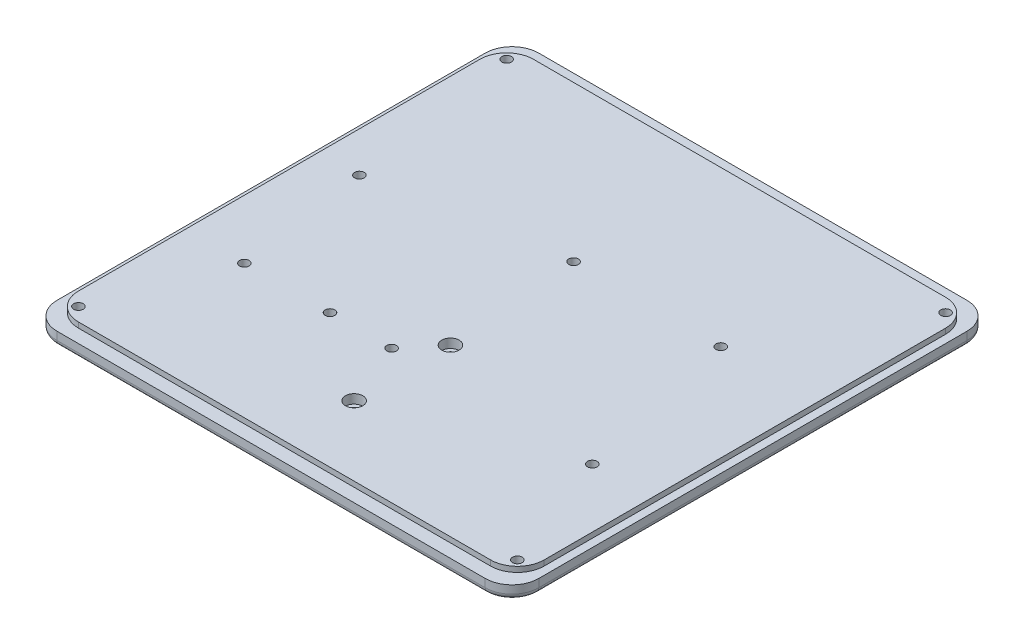
from build123d import *

# Parameters (mm, degrees)
SKIZZE1_W                                            = 180
SKIZZE1_H                                            = 180
AUFSATZ_LINEAR_AUSTRAGEN1_DEPTH                      = 5
AUFSATZ_LINEAR_AUSTRAGEN2_DEPTH                      = 2
STIRNSENKUNG_F_R_M3_ZYLINDERSCHRAUBE_MIT_D           = 3.6
STIRNSENKUNG_F_R_M3_ZYLINDERSCHRAUBE_MIT_DEPTH       = 9.1
STIRNSENKUNG_F_R_M3_ZYLINDERSCHRAUBE_MIT_CBORE_D     = 6.5
STIRNSENKUNG_F_R_M3_ZYLINDERSCHRAUBE_MIT_CBORE_DEPTH = 3.4
STIRNSENKUNG_F_R_M3_ZYLINDERSCHRAUBE_MIT_TIP         = 1.081549114
STIRNSENKUNG_F_R_M3_ZYLINDERSCHRAUBE_2_D             = 3.6
STIRNSENKUNG_F_R_M3_ZYLINDERSCHRAUBE_2_DEPTH         = 9.1
STIRNSENKUNG_F_R_M3_ZYLINDERSCHRAUBE_2_CBORE_D       = 6.5
STIRNSENKUNG_F_R_M3_ZYLINDERSCHRAUBE_2_CBORE_DEPTH   = 3.4
STIRNSENKUNG_F_R_M3_ZYLINDERSCHRAUBE_2_TIP           = 1.081549114
VERRUNDUNG1_R                                        = 10
VERRUNDUNG2_R                                        = 2
STIRNSENKUNG_F_R_M3_ZYLINDERSCHRAUBE_3_D             = 3.6
STIRNSENKUNG_F_R_M3_ZYLINDERSCHRAUBE_3_CBORE_D       = 6.5
STIRNSENKUNG_F_R_M3_ZYLINDERSCHRAUBE_3_CBORE_DEPTH   = 3.4


with BuildPart() as part:
    # Skizze1 → Aufsatz-Linear austragen1 (new body)
    with BuildSketch(Plane(origin=(0, 0, 0), x_dir=(1, 0, 0), z_dir=(0, 1, 0))):
        Rectangle(SKIZZE1_W, SKIZZE1_H)
    extrude(amount=AUFSATZ_LINEAR_AUSTRAGEN1_DEPTH)

    # Skizze2 → Aufsatz-Linear austragen2 (add)
    with BuildSketch(Plane(origin=(0, 5, 0), x_dir=(1, 0, 0), z_dir=(0, 1, 0))):
        with BuildLine():
            Line((77, 85), (-77, 85))
            ThreePointArc((-77, 85), (-84.071067812, 82.071067812), (-87, 75))
            Line((-87, 75), (-87, -75))
            ThreePointArc((-87, -75), (-84.071067812, -82.071067812), (-77, -85))
            Line((-77, -85), (77, -85))
            ThreePointArc((77, -85), (84.071067812, -82.071067812), (87, -75))
            Line((87, -75), (87, 75))
            ThreePointArc((87, 75), (84.071067812, 82.071067812), (77, 85))
        make_face()
    extrude(amount=AUFSATZ_LINEAR_AUSTRAGEN2_DEPTH)

    # Stirnsenkung f_r M3 Zylinderschraube mit
    with Locations(Plane(origin=(0, 7, 0), x_dir=(1, 0, 0), z_dir=(0, 1, 0))):
        with Locations((0, -23), (0, -59)):
            CounterBoreHole(STIRNSENKUNG_F_R_M3_ZYLINDERSCHRAUBE_MIT_D / 2, STIRNSENKUNG_F_R_M3_ZYLINDERSCHRAUBE_MIT_CBORE_D / 2, STIRNSENKUNG_F_R_M3_ZYLINDERSCHRAUBE_MIT_CBORE_DEPTH, depth=STIRNSENKUNG_F_R_M3_ZYLINDERSCHRAUBE_MIT_DEPTH)
            with Locations((0, 0, -(STIRNSENKUNG_F_R_M3_ZYLINDERSCHRAUBE_MIT_DEPTH + STIRNSENKUNG_F_R_M3_ZYLINDERSCHRAUBE_MIT_TIP / 2))):  # 118° drill point
                Cone(0, STIRNSENKUNG_F_R_M3_ZYLINDERSCHRAUBE_MIT_D / 2, STIRNSENKUNG_F_R_M3_ZYLINDERSCHRAUBE_MIT_TIP, mode=Mode.SUBTRACT)

    # Stirnsenkung f_r M3 Zylinderschraube 2
    with Locations(Plane(origin=(0, 0, 0), x_dir=(-1, 0, 0), z_dir=(0, -1, 0))):
        with Locations((-82, 80), (82, 80), (82, -80), (-82, -80)):
            CounterBoreHole(STIRNSENKUNG_F_R_M3_ZYLINDERSCHRAUBE_2_D / 2, STIRNSENKUNG_F_R_M3_ZYLINDERSCHRAUBE_2_CBORE_D / 2, STIRNSENKUNG_F_R_M3_ZYLINDERSCHRAUBE_2_CBORE_DEPTH, depth=STIRNSENKUNG_F_R_M3_ZYLINDERSCHRAUBE_2_DEPTH)
            with Locations((0, 0, -(STIRNSENKUNG_F_R_M3_ZYLINDERSCHRAUBE_2_DEPTH + STIRNSENKUNG_F_R_M3_ZYLINDERSCHRAUBE_2_TIP / 2))):  # 118° drill point
                Cone(0, STIRNSENKUNG_F_R_M3_ZYLINDERSCHRAUBE_2_D / 2, STIRNSENKUNG_F_R_M3_ZYLINDERSCHRAUBE_2_TIP, mode=Mode.SUBTRACT)

    # Verrundung1
    verrundung1_edges = [part.edges().sort_by_distance(p)[0] for p in [
        (90, 2.5, -90),
        (90, 2.5, 90),
        (-90, 2.5, 90),
        (-90, 2.5, -90),
    ]]
    fillet(verrundung1_edges, radius=VERRUNDUNG1_R)

    # Verrundung2
    verrundung2_edges = [part.edges().sort_by_distance(p)[0] for p in [
        (90, 0, 0),
        (0, 0, -90),
        (0, 0, 90),
        (-90, 0, 0),
        (87.071067812, 0, -87.071067812),
        (-87.071067812, 0, -87.071067812),
        (-87.071067812, 0, 87.071067812),
        (87.071067812, 0, 87.071067812),
    ]]
    fillet(verrundung2_edges, radius=VERRUNDUNG2_R)

    # Stirnsenkung f_r M3 Zylinderschraube 3 (through all)
    with Locations(Plane(origin=(0, 0, 0), x_dir=(-1, 0, 0), z_dir=(0, -1, 0))):
        with Locations((-51, 27), (4, 27), (-65, -35), (10, -35), (33, -35), (65, -35), (72, 15)):
            CounterBoreHole(STIRNSENKUNG_F_R_M3_ZYLINDERSCHRAUBE_3_D / 2, STIRNSENKUNG_F_R_M3_ZYLINDERSCHRAUBE_3_CBORE_D / 2, STIRNSENKUNG_F_R_M3_ZYLINDERSCHRAUBE_3_CBORE_DEPTH)


solid = part.part
